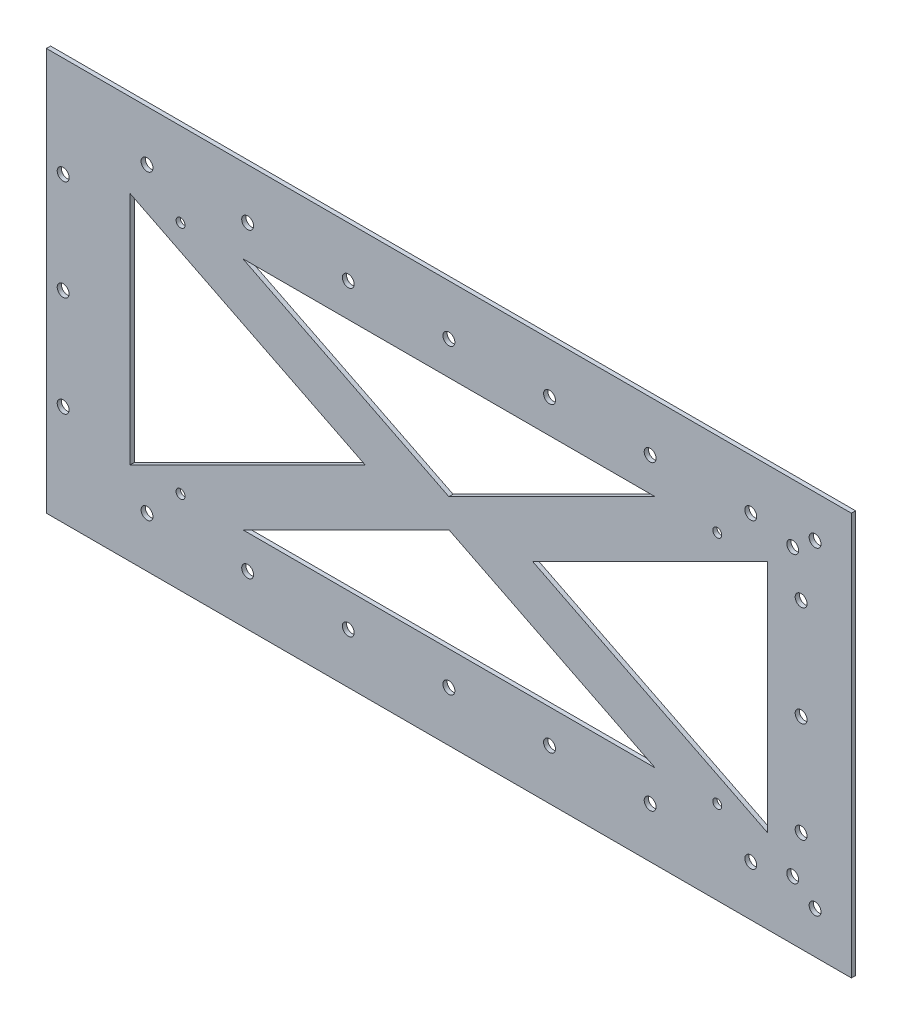
from build123d import *

# Parameters (mm, degrees)
SKETCH1_W           = 304.8
SKETCH1_H           = 152.4
BOSS_EXTRUDE1_DEPTH = 0.79375
SKETCH2_R           = 2.25
CUT_EXTRUDE1_DEPTH  = 2.5875
SKETCH3_R           = 2.25
CUT_EXTRUDE2_DEPTH  = 2.5875
SKETCH4_R           = 1.7
CUT_EXTRUDE3_DEPTH  = 2.5875


with BuildPart() as part:
    # Sketch1 → Boss-Extrude1 (new body, symmetric)
    with BuildSketch(Plane.XY):
        Rectangle(SKETCH1_W, SKETCH1_H)
        Polygon((-120.65, 44.45), (-120.65, -44.45), (-31.75, 0), align=None, mode=Mode.SUBTRACT)
        Polygon((-78.052905029, 44.45), (78.052905029, 44.45), (0, 5.423547486), align=None, mode=Mode.SUBTRACT)
        Polygon((0, -5.423547486), (-78.052905029, -44.45), (78.052905029, -44.45), align=None, mode=Mode.SUBTRACT)
        Polygon((31.75, 0), (120.65, 44.45), (120.65, -44.45), align=None, mode=Mode.SUBTRACT)
    extrude(amount=BOSS_EXTRUDE1_DEPTH, both=True)

    # Sketch2 → Cut-Extrude1 (cut, through all)
    with BuildSketch(Plane.XY.offset(0.79375)):
        with Locations((133.355, 38.1)):
            Circle(SKETCH2_R)
        with Locations((133.355, 0)):
            Circle(SKETCH2_R)
        with Locations((133.355, -38.1)):
            Circle(SKETCH2_R)
        with Locations((114.3, 57.15)):
            Circle(SKETCH2_R)
        with Locations((114.3, -57.15)):
            Circle(SKETCH2_R)
        with Locations((76.2, -57.15)):
            Circle(SKETCH2_R)
        with Locations((76.2, 57.15)):
            Circle(SKETCH2_R)
        with Locations((38.1, -57.15)):
            Circle(SKETCH2_R)
        with Locations((38.1, 57.15)):
            Circle(SKETCH2_R)
        with Locations((0, -57.15)):
            Circle(SKETCH2_R)
        with Locations((0, 57.15)):
            Circle(SKETCH2_R)
        with Locations((-38.1, -57.15)):
            Circle(SKETCH2_R)
        with Locations((-38.1, 57.15)):
            Circle(SKETCH2_R)
        with Locations((-76.2, -57.15)):
            Circle(SKETCH2_R)
        with Locations((-76.2, 57.15)):
            Circle(SKETCH2_R)
        with Locations((-114.3, -57.15)):
            Circle(SKETCH2_R)
        with Locations((-114.3, 57.15)):
            Circle(SKETCH2_R)
        with Locations((130.175, 53.975)):
            Circle(SKETCH2_R)
        with Locations((138.641666667, 60.325)):
            Circle(SKETCH2_R)
        with Locations((130.175, -53.975)):
            Circle(SKETCH2_R)
        with Locations((138.641666667, -60.325)):
            Circle(SKETCH2_R)
    extrude(amount=-CUT_EXTRUDE1_DEPTH, mode=Mode.SUBTRACT)

    # Sketch3 → Cut-Extrude2 (cut, through all)
    with BuildSketch(Plane.XY.offset(0.79375)):
        with Locations((-146.05, 38.1)):
            Circle(SKETCH3_R)
        with Locations((-146.05, -38.1)):
            Circle(SKETCH3_R)
        with Locations((-146.05, 0)):
            Circle(SKETCH3_R)
    extrude(amount=-CUT_EXTRUDE2_DEPTH, mode=Mode.SUBTRACT)

    # Sketch4 → Cut-Extrude3 (cut, through all)
    with BuildSketch(Plane.XY.offset(0.79375)):
        with Locations((-101.6, -44.45)):
            Circle(SKETCH4_R)
        with Locations((101.6, -44.45)):
            Circle(SKETCH4_R)
        with Locations((101.6, 44.45)):
            Circle(SKETCH4_R)
        with Locations((-101.6, 44.45)):
            Circle(SKETCH4_R)
    extrude(amount=-CUT_EXTRUDE3_DEPTH, mode=Mode.SUBTRACT)


solid = part.part
